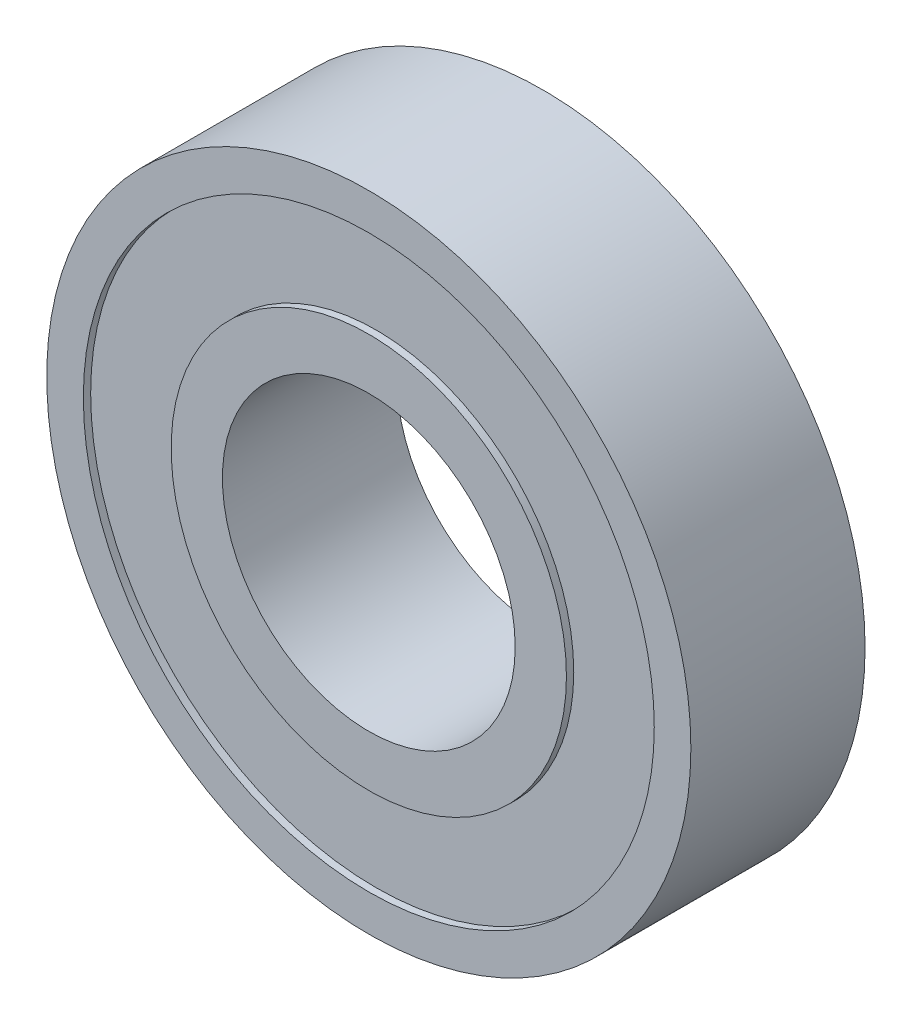
from build123d import *

# Parameters (mm, degrees)
SKETCH3_R           = 11
SKETCH3_R_2         = 5
BOSS_EXTRUDE1_DEPTH = 5.95
SKETCH4_R           = 9.75
SKETCH4_R_2         = 6.75
CUT_EXTRUDE1_DEPTH  = 0.25


with BuildPart() as part:
    # Sketch3 → Boss-Extrude1 (new body)
    with BuildSketch(Plane.XY):
        Circle(SKETCH3_R)
        Circle(SKETCH3_R_2, mode=Mode.SUBTRACT)
    extrude(amount=BOSS_EXTRUDE1_DEPTH)

    # Sketch4 → Cut-Extrude1 (cut)
    with BuildSketch(Plane.XY.offset(5.95)):
        Circle(SKETCH4_R)
        Circle(SKETCH4_R_2, mode=Mode.SUBTRACT)
    cut_extrude1 = extrude(amount=-CUT_EXTRUDE1_DEPTH, mode=Mode.SUBTRACT)

    # Mirror1: Cut-Extrude1 across plane
    add(cut_extrude1.mirror(Plane.XY.offset(2.975)), mode=Mode.SUBTRACT)


solid = part.part
